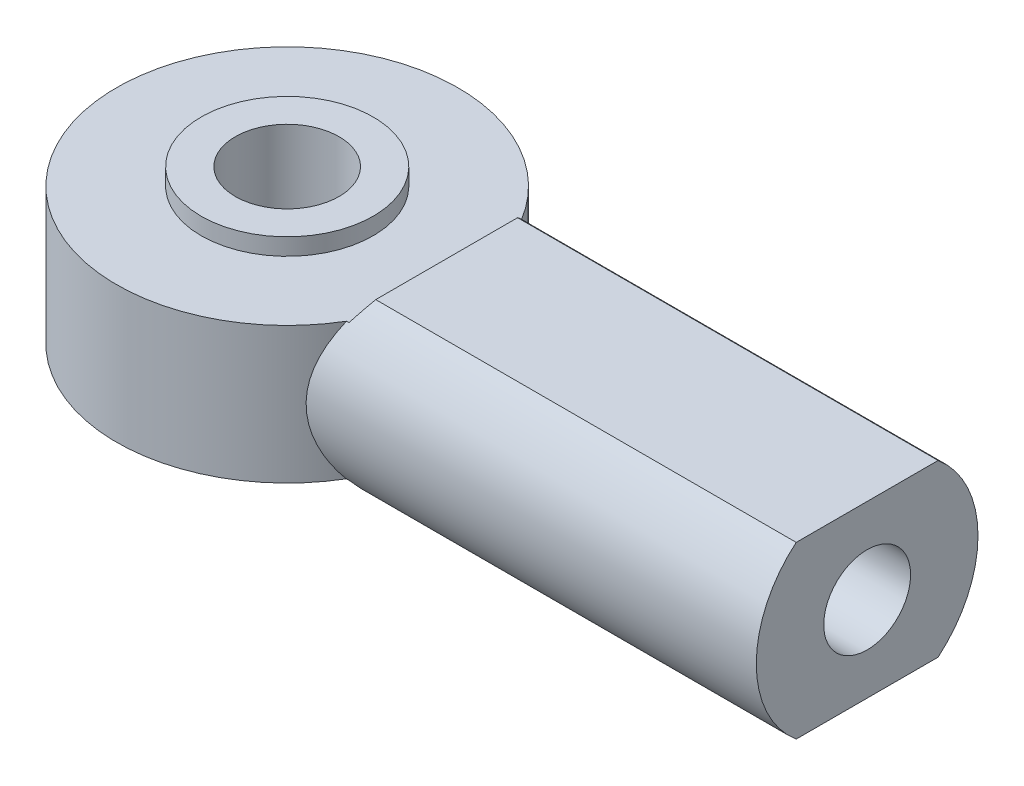
from build123d import *

# Parameters (mm, degrees)
SKETCH1_R                  = 7.9375
HEAD_DIAMETER_DEPTH        = 3.175
BOSS_EXTRUDE4_DEPTH        = 26.9748
CUT_EXTRUDE2_DEPTH         = 7.9375
SKETCH9_R                  = 4.0005
BOSS_EXTRUDE5_DEPTH        = 3.9624
SKETCH10_R                 = 2.413
CUT_EXTRUDE3_DEPTH         = 7.9248
F_10_32_TAPPED_HOLE1_D     = 4.0386
F_10_32_TAPPED_HOLE1_DEPTH = 14.224
F_10_32_TAPPED_HOLE1_TIP   = 1.213317848


with BuildPart() as part:
    # Sketch1 → Head Diameter (new body, symmetric)
    with BuildSketch(Plane(origin=(0, 0, 0), x_dir=(1, 0, 0), z_dir=(0, 1, 0))):
        Circle(SKETCH1_R)
    extrude(amount=HEAD_DIAMETER_DEPTH, both=True)

    # Sketch7 → Boss-Extrude4 (add)
    with BuildSketch(Plane(origin=(0, 0, 0), x_dir=(0, 0, -1), z_dir=(1, 0, 0))):
        with BuildLine():
            Line((-3.299361253, -3.9624), (3.299361253, -3.9624))
            ThreePointArc((3.299361253, -3.9624), (5.1562, 0), (3.299361253, 3.9624))
            Line((3.299361253, 3.9624), (-3.299361253, 3.9624))
            ThreePointArc((-3.299361253, 3.9624), (-5.1562, 0), (-3.299361253, -3.9624))
        make_face()
    extrude(amount=BOSS_EXTRUDE4_DEPTH)

    # Sketch8 → Cut-Extrude2 (cut, symmetric)
    with BuildSketch(Plane.XY):
        Polygon((0, 3.9624), (0, 3.175), (6.9342, 3.175), (7.4168, 3.9624), align=None)
        Polygon((7.4168, -3.9624), (0, -3.9624), (0, -3.175), (6.9342, -3.175), align=None)
    extrude(amount=CUT_EXTRUDE2_DEPTH, both=True, mode=Mode.SUBTRACT)

    # Sketch9 → Boss-Extrude5 (add, symmetric)
    with BuildSketch(Plane(origin=(0, 0, 0), x_dir=(1, 0, 0), z_dir=(0, 1, 0))):
        Circle(SKETCH9_R)
    extrude(amount=BOSS_EXTRUDE5_DEPTH, both=True)

    # Sketch10 → Cut-Extrude3 (cut)
    with BuildSketch(Plane(origin=(0, 3.9624, 0), x_dir=(1, 0, 0), z_dir=(0, 1, 0))):
        Circle(SKETCH10_R)
    extrude(amount=-CUT_EXTRUDE3_DEPTH, mode=Mode.SUBTRACT)

    # #10-32 Tapped Hole1
    with Locations(Plane(origin=(26.9748, 0, 0), x_dir=(0, 0, -1), z_dir=(1, 0, 0))):
        with Locations((0, 0)):
            Hole(F_10_32_TAPPED_HOLE1_D / 2, depth=F_10_32_TAPPED_HOLE1_DEPTH)
            with Locations((0, 0, -(F_10_32_TAPPED_HOLE1_DEPTH + F_10_32_TAPPED_HOLE1_TIP / 2))):  # 118° drill point
                Cone(0, F_10_32_TAPPED_HOLE1_D / 2, F_10_32_TAPPED_HOLE1_TIP, mode=Mode.SUBTRACT)


solid = part.part
